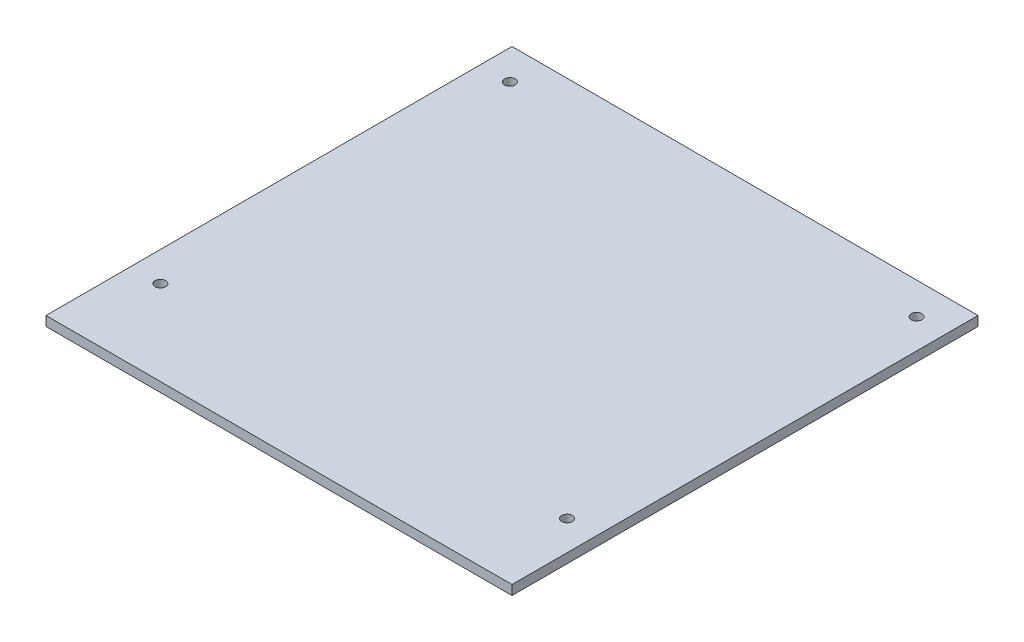
from build123d import *

# Parameters (mm, degrees)
SKETCH1_W           = 220
SKETCH1_H           = 220
BOSS_EXTRUDE1_DEPTH = 4.5
SKETCH2_R           = 2.5
CUT_EXTRUDE1_DEPTH  = 5.5


with BuildPart() as part:
    # Sketch1 → Boss-Extrude1 (new body)
    with BuildSketch(Plane(origin=(0, 0, 0), x_dir=(1, 0, 0), z_dir=(0, 1, 0))):
        Rectangle(SKETCH1_W, SKETCH1_H)
    extrude(amount=BOSS_EXTRUDE1_DEPTH)

    # Sketch2 → Cut-Extrude1 (cut, through all)
    with BuildSketch(Plane(origin=(0, 4.5, 0), x_dir=(1, 0, 0), z_dir=(0, 1, 0))):
        with Locations((96, -70)):
            Circle(SKETCH2_R)
        with Locations((-96, -70)):
            Circle(SKETCH2_R)
        with Locations((-96, 95)):
            Circle(SKETCH2_R)
        with Locations((96, 95)):
            Circle(SKETCH2_R)
    extrude(amount=-CUT_EXTRUDE1_DEPTH, mode=Mode.SUBTRACT)


solid = part.part
